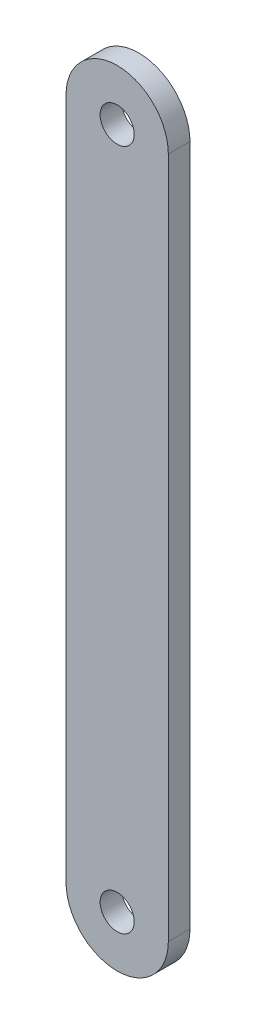
from build123d import *

# Parameters (mm, degrees)
ESBO_O1_R                = 5
RESSALTO_EXTRUS_O1_DEPTH = 6.35


with BuildPart() as part:
    # Esboço1 → Ressalto-extrusão1 (new body)
    with BuildSketch(Plane.XY):
        with BuildLine():
            Line((-15, 0), (-15, 200))
            ThreePointArc((-15, 200), (0, 215), (15, 200))
            Line((15, 200), (15, 0))
            ThreePointArc((15, 0), (0, -15), (-15, 0))
        make_face()
        with Locations((0, 200)):
            Circle(ESBO_O1_R, mode=Mode.SUBTRACT)
        Circle(ESBO_O1_R, mode=Mode.SUBTRACT)
    extrude(amount=RESSALTO_EXTRUS_O1_DEPTH)


solid = part.part
